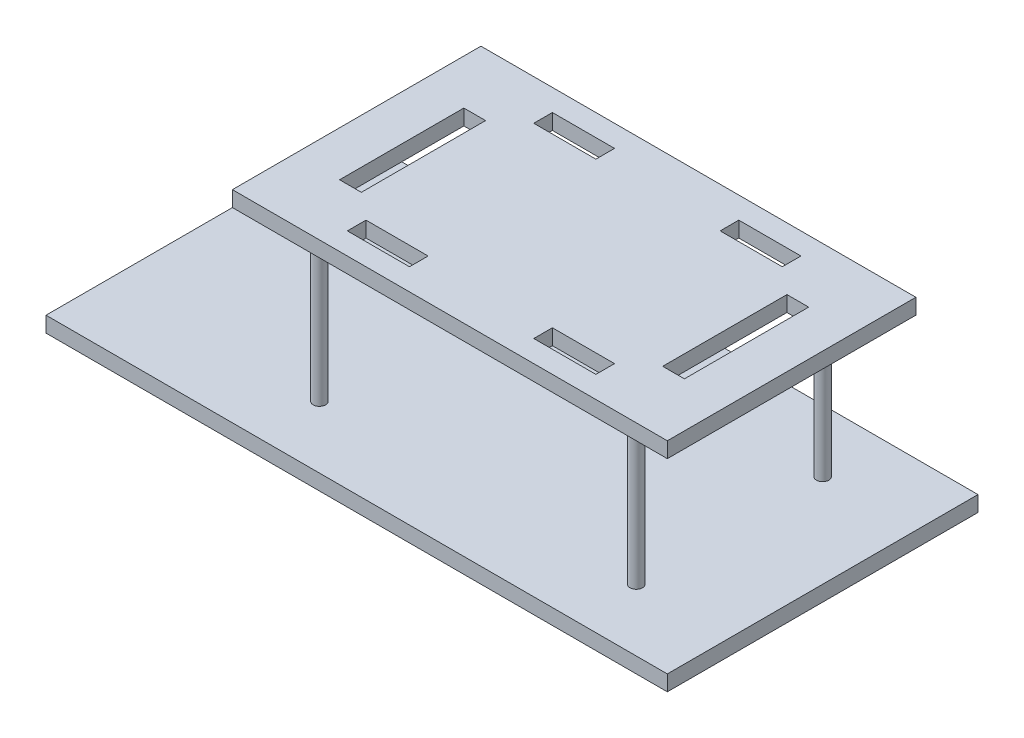
from build123d import *

# Parameters (mm, degrees)
SKETCH1_W           = 200
SKETCH1_H           = 100
BOSS_EXTRUDE2_DEPTH = 5
SKETCH2_R           = 2
BOSS_EXTRUDE3_DEPTH = 50
SKETCH3_W           = 140
SKETCH3_H           = 80
BOSS_EXTRUDE4_DEPTH = 5
SKETCH4_W           = 20
SKETCH4_H           = 6
CUT_EXTRUDE1_DEPTH  = 5
SKETCH7_W           = 7
SKETCH7_H           = 40
CUT_EXTRUDE2_DEPTH  = 5


with BuildPart() as part:
    # Sketch1 → Boss-Extrude2 (new body)
    with BuildSketch(Plane(origin=(0, 0, 0), x_dir=(1, 0, 0), z_dir=(0, 1, 0))):
        Rectangle(SKETCH1_W, SKETCH1_H)
    extrude(amount=BOSS_EXTRUDE2_DEPTH)

    # Sketch2 → Boss-Extrude3 (add)
    with BuildSketch(Plane(origin=(0, 5, 0), x_dir=(1, 0, 0), z_dir=(0, 1, 0))):
        with Locations((70, -30)):
            Circle(SKETCH2_R)
        with Locations((-32, -30)):
            Circle(SKETCH2_R)
        with Locations((70, 30)):
            Circle(SKETCH2_R)
        with Locations((-32, 30)):
            Circle(SKETCH2_R)
    extrude(amount=BOSS_EXTRUDE3_DEPTH)

    # Sketch3 → Boss-Extrude4 (add)
    with BuildSketch(Plane(origin=(0, 55, 0), x_dir=(1, 0, 0), z_dir=(0, 1, 0))):
        with Locations((20, 0)):
            Rectangle(SKETCH3_W, SKETCH3_H)
    extrude(amount=BOSS_EXTRUDE4_DEPTH)

    # Sketch4 → Cut-Extrude1 (cut)
    with BuildSketch(Plane(origin=(0, 60, 0), x_dir=(1, 0, 0), z_dir=(0, 1, 0))):
        with Locations((-10, 30)):
            Rectangle(SKETCH4_W, SKETCH4_H)
        with Locations((-10, -30)):
            Rectangle(SKETCH4_W, SKETCH4_H)
        with Locations((50, -30)):
            Rectangle(SKETCH4_W, SKETCH4_H)
        with Locations((50, 30)):
            Rectangle(SKETCH4_W, SKETCH4_H)
    extrude(amount=-CUT_EXTRUDE1_DEPTH, mode=Mode.SUBTRACT)

    # Sketch7 → Cut-Extrude2 (cut)
    with BuildSketch(Plane(origin=(0, 60, 0), x_dir=(1, 0, 0), z_dir=(0, 1, 0))):
        with Locations((-32, 0)):
            Rectangle(SKETCH7_W, SKETCH7_H)
        with Locations((72, 0)):
            Rectangle(SKETCH7_W, SKETCH7_H)
    extrude(amount=-CUT_EXTRUDE2_DEPTH, mode=Mode.SUBTRACT)


solid = part.part
